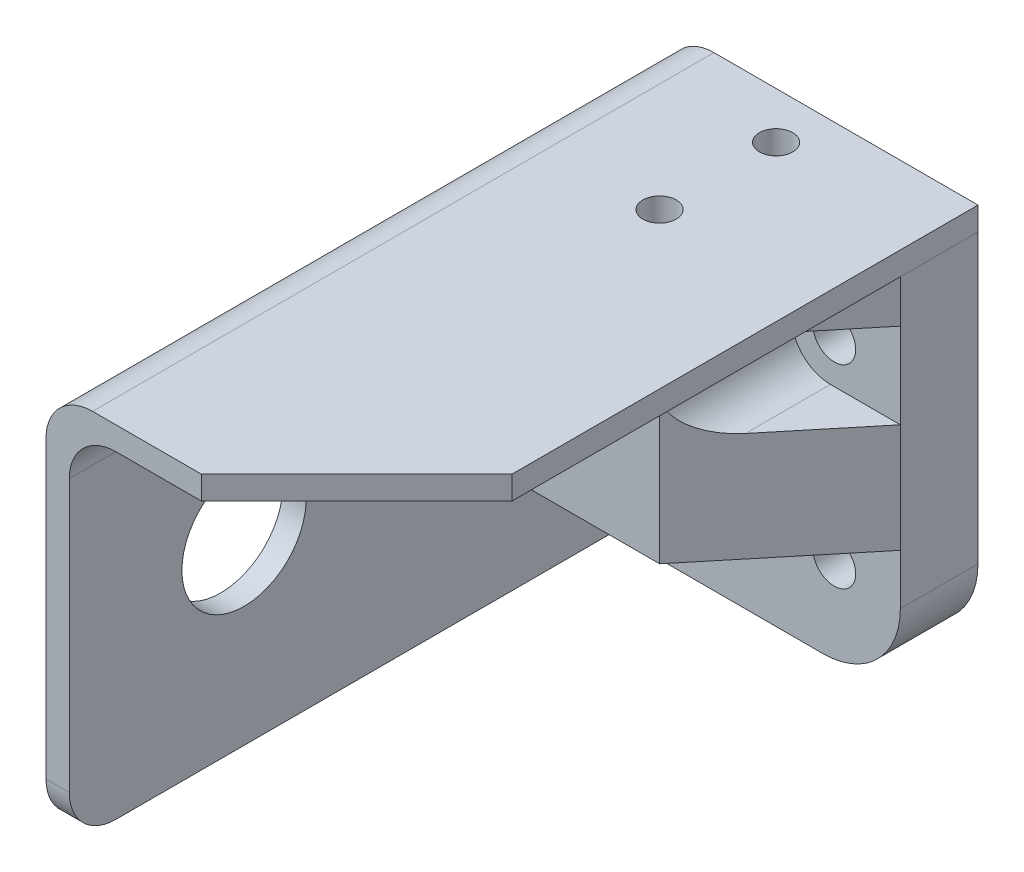
from build123d import *

# Parameters (mm, degrees)
EXTRUDE_THIN1_DEPTH     = 80
SKETCH2_R               = 8
CUT_EXTRUDE1_DEPTH      = 10
FILLET1_R               = 6
CHAMFER1_SIZE           = 20
SKETCH3_R               = 2.75
BOSS_EXTRUDE1_DEPTH     = 27
SKETCH4_R               = 2.15
CUT_EXTRUDE2_DEPTH      = 22
SKETCH5_R               = 5.5
SKETCH5_W               = 34
SKETCH5_H               = 16.5
SKETCH5_W_2             = 14
SKETCH5_H_2             = 11
CUT_EXTRUDE3_DEPTH      = 17
SKETCH6_R               = 2.15
CUT_EXTRUDE4_DEPTH      = 21
CUT_EXTRUDE5_DEPTH      = 42.5
CUT_EXTRUDE5_DEPTH_BACK = 5.5
CUT_EXTRUDE6_DEPTH      = 3
FILLET6_R               = 10
FILLET7_R               = 5


with BuildPart() as part:
    # Sketch1 → Extrude-Thin1 (new body)
    with BuildSketch(Plane.XY):
        Polygon((0, 0), (0, 50), (40, 50), (40, 47), (3, 47), (3, 0), align=None)
    extrude(amount=EXTRUDE_THIN1_DEPTH)

    # Sketch2 → Cut-Extrude1 (cut)
    with BuildSketch(Plane.ZY):
        with Locations((57.5, 23.5)):
            Circle(SKETCH2_R)
    extrude(amount=-CUT_EXTRUDE1_DEPTH, mode=Mode.SUBTRACT)

    # Fillet1
    fillet1_edges = [part.edges().sort_by_distance(p)[0] for p in [
        (1.5, 0, 80),
        (3, 47, 40),
        (0, 50, 40),
    ]]
    fillet(fillet1_edges, radius=FILLET1_R)

    # Chamfer1
    chamfer1_edges = [part.edges().sort_by_distance(p)[0] for p in [
        (40, 48.5, 80),
    ]]
    chamfer(chamfer1_edges, length=CHAMFER1_SIZE)


with BuildPart() as body_2:
    # Sketch3 → Boss-Extrude1 (new body)
    with BuildSketch(Plane(origin=(0, 0, 0), x_dir=(-1, 0, 0), z_dir=(0, 0, -1))):
        with BuildLine():
            Line((-40, 47), (-40, 0))
            Line((-40, 0), (-3, 0))
            Line((-3, 0), (-3, 41))
            ThreePointArc((-3, 41), (-4.757359313, 45.242640687), (-9, 47))
            Line((-9, 47), (-40, 47))
        make_face()
        with Locations((-31.5, 36)):
            Circle(SKETCH3_R, mode=Mode.SUBTRACT)
        with Locations((-11.5, 36)):
            Circle(SKETCH3_R, mode=Mode.SUBTRACT)
        with Locations((-11.5, 11)):
            Circle(SKETCH3_R, mode=Mode.SUBTRACT)
        with Locations((-31.5, 11)):
            Circle(SKETCH3_R, mode=Mode.SUBTRACT)
    extrude(amount=-BOSS_EXTRUDE1_DEPTH)


with BuildPart() as cut_extrude2_tool:
    # Sketch4 → Cut-Extrude2 (new body)
    with BuildSketch(Plane.ZY):
        with Locations((7, 25)):
            Circle(SKETCH4_R)
        with Locations((20, 25)):
            Circle(SKETCH4_R)
    extrude(amount=-CUT_EXTRUDE2_DEPTH)


with BuildPart() as part_1:
    add(part.part)

    # Cut-Extrude2: cut by cut_extrude2_tool
    add(cut_extrude2_tool.part, mode=Mode.SUBTRACT)


with BuildPart() as body_2_1:
    add(body_2.part)

    # Cut-Extrude2: cut by cut_extrude2_tool
    add(cut_extrude2_tool.part, mode=Mode.SUBTRACT)

    # Sketch5 → Cut-Extrude3 (cut)
    with BuildSketch(Plane.XY.offset(27)):
        with Locations((11.5, 36)):
            Circle(SKETCH5_R)
        with Locations((23, 8.25)):
            Rectangle(SKETCH5_W, SKETCH5_H)
        with Locations((33, 36)):
            Rectangle(SKETCH5_W_2, SKETCH5_H_2)
    extrude(amount=-CUT_EXTRUDE3_DEPTH, mode=Mode.SUBTRACT)


with BuildPart() as cut_extrude4_tool:
    # Sketch6 → Cut-Extrude4 (new body)
    with BuildSketch(Plane(origin=(0, 50, 0), x_dir=(1, 0, 0), z_dir=(0, 1, 0))):
        with Locations((20, -6)):
            Circle(SKETCH6_R)
        with Locations((20, -21)):
            Circle(SKETCH6_R)
    extrude(amount=-CUT_EXTRUDE4_DEPTH)


with BuildPart() as part_2:
    add(part_1.part)

    # Cut-Extrude4: cut by cut_extrude4_tool
    add(cut_extrude4_tool.part, mode=Mode.SUBTRACT)


with BuildPart() as body_2_2:
    add(body_2_1.part)

    # Cut-Extrude4: cut by cut_extrude4_tool
    add(cut_extrude4_tool.part, mode=Mode.SUBTRACT)

    # Sketch7 → Cut-Extrude5 (cut, two sides)
    with BuildSketch(Plane.XZ.offset(-41.5)) as cut_extrude5_sk:
        Polygon((26, 27), (40, 10), (40, 27), align=None)
    extrude(amount=CUT_EXTRUDE5_DEPTH, mode=Mode.SUBTRACT)
    extrude(cut_extrude5_sk.sketch, amount=-CUT_EXTRUDE5_DEPTH_BACK, mode=Mode.SUBTRACT)

    # Sketch8 → Cut-Extrude6 (cut)
    with BuildSketch(Plane(origin=(6, 0, 0), x_dir=(0, 0, -1), z_dir=(1, 0, 0))):
        Polygon((-27, 16.5), (-10, 0), (-27, 0), align=None)
    extrude(amount=-CUT_EXTRUDE6_DEPTH, mode=Mode.SUBTRACT)

    # Fillet6
    fillet6_edges = [body_2_2.edges().sort_by_distance(p)[0] for p in [
        (40, 0, 5),
    ]]
    fillet(fillet6_edges, radius=FILLET6_R)

    # Fillet7
    fillet7_edges = [body_2_2.edges().sort_by_distance(p)[0] for p in [
        (6, 16.5, 18.5),
        (26, 30.5, 18.5),
        (26, 41.5, 18.5),
    ]]
    fillet(fillet7_edges, radius=FILLET7_R)


solid = Compound([part_2.part, body_2_2.part])
